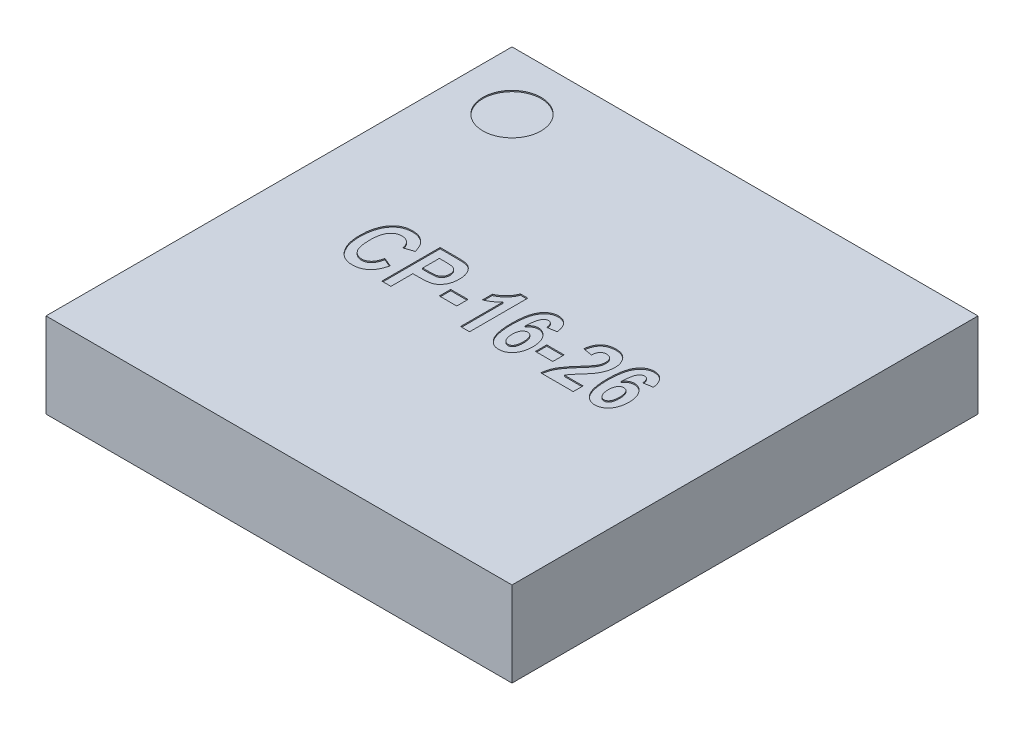
from build123d import *

# Parameters (mm, degrees)
SKETCH1_W           = 4
SKETCH1_H           = 4
BOSS_EXTRUDE1_DEPTH = 0.73
SKETCH2_R           = 0.25
CUT_EXTRUDE1_DEPTH  = 0.01
SKETCH3_W           = 0.14935065
SKETCH3_H           = 0.097402598
SKETCH3_W_2         = 0.149350649
CUT_EXTRUDE2_DEPTH  = 0.01


with BuildPart() as part:
    # Sketch1 → Boss-Extrude1 (new body)
    with BuildSketch(Plane(origin=(0, 0, 0), x_dir=(1, 0, 0), z_dir=(0, 1, 0))):
        Rectangle(SKETCH1_W, SKETCH1_H)
    extrude(amount=BOSS_EXTRUDE1_DEPTH)

    # Sketch2 → Cut-Extrude1 (cut)
    with BuildSketch(Plane(origin=(0, 0.73, 0), x_dir=(1, 0, 0), z_dir=(0, 1, 0))):
        with Locations(Location((-1.5, 1.5, 0), (0, 0, 270))):
            Circle(SKETCH2_R)
    extrude(amount=-CUT_EXTRUDE1_DEPTH, mode=Mode.SUBTRACT)

    # Sketch3 → Cut-Extrude2 (cut)
    with BuildSketch(Plane(origin=(0, 0.73, 0), x_dir=(1, 0, 0), z_dir=(0, 1, 0))):
        with BuildLine():
            Line((-0.973076704, -0.118181818), (-0.895154626, -0.150649351))
            add(Edge.make_bspline(
                [(-0.895154626, -0.150649351), (-0.896763939, -0.157199419), (-0.899899765, -0.169962551), (-0.905832316, -0.188204654), (-0.91236041, -0.205130547), (-0.919828916, -0.22064549), (-0.927981778, -0.2348856), (-0.937037949, -0.24771075), (-0.946827045, -0.259186605), (-0.957404745, -0.269286352), (-0.968753893, -0.277976376), (-0.980555836, -0.28572007), (-0.993115333, -0.29206825), (-1.006256518, -0.297428311), (-1.020082704, -0.301412625), (-1.034488844, -0.304410987), (-1.049536773, -0.306126789), (-1.059787871, -0.306369892), (-1.065000405, -0.306493506)],
                knots=[0, 0, 0, 0, 1.282586353, 2.499182829, 3.646034602, 4.730797578, 5.771318175, 6.763713287, 7.712684321, 8.6363956, 9.539720391, 10.428356747, 11.317388874, 12.212151588, 13.124116906, 14.050177375, 15.008543639, 16, 16, 16, 16], degree=3))
            add(Edge.make_bspline(
                [(-1.065000405, -0.306493506), (-1.071540548, -0.306346468), (-1.084352535, -0.306058423), (-1.103047685, -0.302959131), (-1.120837731, -0.298250296), (-1.137690604, -0.29148838), (-1.15362629, -0.282845212), (-1.168476442, -0.272139378), (-1.182587573, -0.259769439), (-1.190792225, -0.250124533), (-1.194971996, -0.245211039)],
                knots=[0, 0, 0, 0, 1.053414494, 2.063614103, 3.046293227, 4.01520277, 4.983805463, 5.961130836, 6.961320097, 8, 8, 8, 8], degree=3))
            add(Edge.make_bspline(
                [(-1.194971996, -0.245211039), (-1.199566404, -0.239144714), (-1.208822264, -0.226923542), (-1.220442483, -0.206770852), (-1.230325702, -0.185120172), (-1.23841463, -0.161951881), (-1.244719522, -0.13724031), (-1.249127461, -0.110973678), (-1.251774562, -0.083164691), (-1.252120533, -0.064109002), (-1.252297483, -0.054362825)],
                knots=[0, 0, 0, 0, 0.898140554, 1.809387162, 2.740718204, 3.705966939, 4.703925369, 5.74945803, 6.848943185, 8, 8, 8, 8], degree=3))
            add(Edge.make_bspline(
                [(-1.252297483, -0.054362825), (-1.252135827, -0.044074357), (-1.251820947, -0.024034148), (-1.248985936, 0.005142491), (-1.244664082, 0.032649117), (-1.238220378, 0.058383494), (-1.230148219, 0.082493389), (-1.220175089, 0.104828456), (-1.208595285, 0.125622287), (-1.199147489, 0.138041064), (-1.194464691, 0.144196429)],
                knots=[0, 0, 0, 0, 1.171098873, 2.281104103, 3.334483992, 4.338438261, 5.297974877, 6.225356982, 7.120398547, 8, 8, 8, 8], degree=3))
            add(Edge.make_bspline(
                [(-1.194464691, 0.144196429), (-1.190212941, 0.14917207), (-1.181833655, 0.158977992), (-1.167511461, 0.171675972), (-1.152124929, 0.182469708), (-1.135679624, 0.191307035), (-1.118101962, 0.19818042), (-1.099477972, 0.203030388), (-1.079733085, 0.205892063), (-1.066227429, 0.206289961), (-1.059318587, 0.206493506)],
                knots=[0, 0, 0, 0, 1.017460211, 2.005195831, 2.96880208, 3.936538458, 4.903086366, 5.898753713, 6.925103759, 8, 8, 8, 8], degree=3))
            add(Edge.make_bspline(
                [(-1.059318587, 0.206493506), (-1.053664634, 0.206358172), (-1.042552054, 0.206092177), (-1.02625747, 0.203965699), (-1.010732874, 0.200226584), (-0.995826721, 0.195322032), (-0.981669791, 0.188759793), (-0.968221148, 0.180796898), (-0.955427905, 0.171459527), (-0.947673719, 0.164200592), (-0.943754463, 0.160531656)],
                knots=[0, 0, 0, 0, 1.062174293, 2.087653736, 3.080296642, 4.058948008, 5.03139012, 6.005719887, 6.992016441, 8, 8, 8, 8], degree=3))
            add(Edge.make_bspline(
                [(-0.943754463, 0.160531656), (-0.941029443, 0.157703941), (-0.935476619, 0.151941852), (-0.927999728, 0.142235974), (-0.921077424, 0.13154683), (-0.914833817, 0.119828804), (-0.909029334, 0.107196426), (-0.903751219, 0.093584945), (-0.899107948, 0.078963394), (-0.896492758, 0.068824301), (-0.895154626, 0.063636364)],
                knots=[0, 0, 0, 0, 0.858002413, 1.748367619, 2.673305357, 3.63929672, 4.648357542, 5.711115493, 6.828831091, 8, 8, 8, 8], degree=3))
            Line((-0.895154626, 0.063636364), (-0.973076704, 0.037662338))
            add(Edge.make_bspline(
                [(-0.973076704, 0.037662338), (-0.973808933, 0.040987951), (-0.97523373, 0.047459042), (-0.978094361, 0.056797707), (-0.981577064, 0.065471471), (-0.98536629, 0.073688559), (-0.98992915, 0.081164757), (-0.994702044, 0.08825728), (-1.00029871, 0.09454098), (-1.006211433, 0.100346042), (-1.012648771, 0.105362577), (-1.019237965, 0.109899251), (-1.026175464, 0.113671163), (-1.03343233, 0.116704728), (-1.040922612, 0.119159799), (-1.048702123, 0.120886266), (-1.056753061, 0.121931755), (-1.062223945, 0.122028715), (-1.065000405, 0.122077922)],
                knots=[0, 0, 0, 0, 1.200071046, 2.335138942, 3.437621639, 4.493482591, 5.51985659, 6.521917265, 7.50210956, 8.480124453, 9.438987346, 10.374745328, 11.297656865, 12.216555725, 13.143999084, 14.072438006, 15.021767148, 16, 16, 16, 16], degree=3))
            add(Edge.make_bspline(
                [(-1.065000405, 0.122077922), (-1.068929785, 0.12196142), (-1.076663206, 0.121732133), (-1.087993334, 0.119907877), (-1.098713174, 0.116681277), (-1.108984117, 0.112445387), (-1.118633574, 0.106801919), (-1.127768964, 0.0999676), (-1.136144648, 0.091735893), (-1.144171857, 0.082476634), (-1.151445867, 0.07174862), (-1.157621998, 0.059349888), (-1.162716186, 0.045324702), (-1.167104227, 0.029773649), (-1.170387289, 0.012594558), (-1.172665633, -0.006185968), (-1.174087576, -0.026540695), (-1.174277256, -0.040663143), (-1.174375405, -0.047970779)],
                knots=[0, 0, 0, 0, 0.827686898, 1.628972485, 2.409099021, 3.181967192, 3.964173723, 4.757978677, 5.579415306, 6.433460257, 7.33665582, 8.302235029, 9.343905073, 10.476376866, 11.703364719, 13.024698166, 14.460435141, 16, 16, 16, 16], degree=3))
            add(Edge.make_bspline(
                [(-1.174375405, -0.047970779), (-1.174264501, -0.055547936), (-1.174050934, -0.070139244), (-1.172806011, -0.091213985), (-1.170439707, -0.110576844), (-1.167410658, -0.128303959), (-1.163265689, -0.144291712), (-1.158201808, -0.158549895), (-1.152369023, -0.171217707), (-1.145411136, -0.182128944), (-1.13770166, -0.191548589), (-1.129505076, -0.199726893), (-1.120663142, -0.206558729), (-1.111412401, -0.21234867), (-1.101498884, -0.216736134), (-1.091039872, -0.219721266), (-1.080097393, -0.221785937), (-1.072586065, -0.221979291), (-1.068754463, -0.222077922)],
                knots=[0, 0, 0, 0, 1.588381619, 3.058741945, 4.422565575, 5.675514383, 6.825848758, 7.879737597, 8.8437938, 9.742560847, 10.584031071, 11.391113559, 12.163968987, 12.921455088, 13.673648094, 14.427376256, 15.197789283, 16, 16, 16, 16], degree=3))
            add(Edge.make_bspline(
                [(-1.068754463, -0.222077922), (-1.065944307, -0.22199089), (-1.060369744, -0.221818242), (-1.052166727, -0.220718873), (-1.044250952, -0.218753222), (-1.036621354, -0.216026103), (-1.029310448, -0.212428018), (-1.022243224, -0.208165333), (-1.015562451, -0.203041538), (-1.009094776, -0.197223721), (-1.002994592, -0.190532204), (-0.997419491, -0.182838844), (-0.992239591, -0.174281141), (-0.987486208, -0.164806021), (-0.983129027, -0.154474384), (-0.979287274, -0.143206945), (-0.975810844, -0.131059958), (-0.974005638, -0.122557215), (-0.973076704, -0.118181818)],
                knots=[0, 0, 0, 0, 0.874040642, 1.73385169, 2.568061146, 3.406503852, 4.248567505, 5.09821747, 5.96915136, 6.862782357, 7.800986125, 8.779254107, 9.812897901, 10.908933612, 12.073249979, 13.297367906, 14.609261928, 16, 16, 16, 16], degree=3))
        make_face()
        with BuildLine():
            Line((-0.817232548, -0.3), (-0.817232548, 0.2))
            Line((-0.817232548, 0.2), (-0.682492288, 0.2))
            add(Edge.make_bspline(
                [(-0.682492288, 0.2), (-0.676506055, 0.199978894), (-0.665040044, 0.199938468), (-0.648666442, 0.199680898), (-0.633885466, 0.199050328), (-0.620758852, 0.198268717), (-0.609250063, 0.19728203), (-0.599405721, 0.196060775), (-0.591132358, 0.194778211), (-0.586264417, 0.193411113), (-0.58407508, 0.192796266)],
                knots=[0, 0, 0, 0, 1.45237712, 2.781878126, 3.972677768, 5.041396282, 5.972228918, 6.774219171, 7.448710173, 8, 8, 8, 8], degree=3))
            add(Edge.make_bspline(
                [(-0.58407508, 0.192796266), (-0.581044762, 0.191731788), (-0.575015397, 0.189613815), (-0.566299606, 0.185501934), (-0.558002232, 0.180549176), (-0.550144372, 0.174706292), (-0.542719161, 0.168076827), (-0.535664038, 0.160632241), (-0.529132382, 0.152288585), (-0.522899412, 0.143245054), (-0.517241573, 0.133470711), (-0.512328069, 0.12295398), (-0.508331928, 0.111709638), (-0.504827395, 0.099843654), (-0.502223082, 0.087250793), (-0.500431121, 0.073993169), (-0.499290731, 0.060071219), (-0.499131974, 0.050550155), (-0.49905073, 0.04567776)],
                knots=[0, 0, 0, 0, 0.846149961, 1.683567978, 2.535100776, 3.389102938, 4.260422696, 5.155850399, 6.088615247, 7.050446182, 8.048882284, 9.061856799, 10.105243332, 11.191356413, 12.320760927, 13.490669576, 14.715852464, 16, 16, 16, 16], degree=3))
            add(Edge.make_bspline(
                [(-0.49905073, 0.04567776), (-0.499097377, 0.041245033), (-0.499189021, 0.032536483), (-0.500256924, 0.019771051), (-0.501838249, 0.007532477), (-0.504152847, -0.004135746), (-0.50722735, -0.015239251), (-0.510884023, -0.025813078), (-0.51509828, -0.035894341), (-0.520108127, -0.045313008), (-0.525570873, -0.05409955), (-0.531377636, -0.062284165), (-0.537511576, -0.069749543), (-0.544022337, -0.076526498), (-0.550729836, -0.082767331), (-0.558010988, -0.088074434), (-0.565429557, -0.092941533), (-0.573427693, -0.097108949), (-0.582356815, -0.100563844), (-0.592485852, -0.103631762), (-0.604063439, -0.106105913), (-0.617079745, -0.108085171), (-0.631533635, -0.109692148), (-0.647403459, -0.110896543), (-0.664730046, -0.111606538), (-0.676742136, -0.111660304), (-0.682999593, -0.111688312)],
                knots=[0, 0, 0, 0, 1.135396723, 2.23060449, 3.279591759, 4.295786631, 5.275377901, 6.228987074, 7.160814112, 8.071657328, 8.958908755, 9.810053931, 10.641024385, 11.43162038, 12.216736813, 12.984447025, 13.736746148, 14.488596033, 15.289898233, 16.186242141, 17.197511819, 18.320073528, 19.558272269, 20.922626145, 22.396903763, 24, 24, 24, 24], degree=3))
            Line((-0.682999593, -0.111688312), (-0.73931047, -0.111688312))
            Line((-0.73931047, -0.111688312), (-0.73931047, -0.3))
            Line((-0.73931047, -0.3), (-0.817232548, -0.3))
        make_face()
        with BuildLine():
            Line((-0.73931047, 0.115584416), (-0.73931047, -0.027272727))
            Line((-0.73931047, -0.027272727), (-0.688478489, -0.027272727))
            add(Edge.make_bspline(
                [(-0.688478489, -0.027272727), (-0.684386018, -0.027255014), (-0.676538054, -0.027221045), (-0.66527331, -0.026917143), (-0.655021864, -0.026425177), (-0.645784181, -0.025725411), (-0.637589279, -0.024844774), (-0.630412102, -0.023723247), (-0.624263546, -0.022465533), (-0.617474305, -0.020460522), (-0.610030234, -0.017024981), (-0.601966556, -0.011749513), (-0.594759598, -0.005120391), (-0.588456328, 0.002712585), (-0.583253723, 0.011715126), (-0.579634823, 0.021821924), (-0.57730765, 0.032821603), (-0.577087011, 0.040490702), (-0.576972808, 0.044460227)],
                knots=[0, 0, 0, 0, 1.284283312, 2.462817476, 3.536098701, 4.504784959, 5.369772942, 6.121838585, 6.783804212, 7.337847747, 8.3400838, 9.343892165, 10.350558075, 11.399797468, 12.488501389, 13.596588458, 14.755994231, 16, 16, 16, 16], degree=3))
            add(Edge.make_bspline(
                [(-0.576972808, 0.044460227), (-0.577077394, 0.048499219), (-0.577279719, 0.056312732), (-0.5797385, 0.067471943), (-0.583409042, 0.077730611), (-0.588909908, 0.086705817), (-0.595235052, 0.094605746), (-0.602378721, 0.101271073), (-0.610434049, 0.106232085), (-0.617763387, 0.109420324), (-0.624493582, 0.111310853), (-0.630864798, 0.112330506), (-0.638443717, 0.113331868), (-0.647267926, 0.114278415), (-0.657324799, 0.114828493), (-0.668623951, 0.115204666), (-0.681171434, 0.1155409), (-0.689966328, 0.115569472), (-0.694566152, 0.115584416)],
                knots=[0, 0, 0, 0, 1.217310155, 2.3549115, 3.434183208, 4.491984437, 5.51587148, 6.484436833, 7.425091316, 8.358344432, 8.888574254, 9.53159621, 10.304262475, 11.197434113, 12.210261746, 13.34451227, 14.611151563, 16, 16, 16, 16], degree=3))
            Line((-0.694566152, 0.115584416), (-0.73931047, 0.115584416))
        make_face(mode=Mode.SUBTRACT)
        with Locations((-0.385414366, -0.114935065)):
            Rectangle(SKETCH3_W, SKETCH3_H)
        with BuildLine():
            Line((-0.063985795, -0.3), (-0.141907873, -0.3))
            Line((-0.141907873, -0.3), (-0.141907873, 0.063636364))
            add(Edge.make_bspline(
                [(-0.141907873, 0.063636364), (-0.145687077, 0.059670682), (-0.153182123, 0.051805807), (-0.165106191, 0.040826148), (-0.177442654, 0.030703473), (-0.190272917, 0.021391888), (-0.203450172, 0.012803013), (-0.217141118, 0.005050422), (-0.231229664, -0.001882073), (-0.240942365, -0.00582074), (-0.245803976, -0.007792208)],
                knots=[0, 0, 0, 0, 1.033480345, 2.049633457, 3.05634389, 4.043072978, 5.039658923, 6.022790494, 7.010324124, 8, 8, 8, 8], degree=3))
            Line((-0.245803976, -0.007792208), (-0.245803976, 0.076623377))
            add(Edge.make_bspline(
                [(-0.245803976, 0.076623377), (-0.24020024, 0.079113926), (-0.228533577, 0.084299109), (-0.211465855, 0.094709877), (-0.194228143, 0.10774717), (-0.179925092, 0.120261945), (-0.168769238, 0.131396363), (-0.160820295, 0.140166089), (-0.153703941, 0.149428979), (-0.147108896, 0.158854386), (-0.141285903, 0.168711853), (-0.136145015, 0.17881214), (-0.131583266, 0.189221134), (-0.129203775, 0.196394344), (-0.12800771, 0.2)],
                knots=[0, 0, 0, 0, 1.256071058, 2.615068939, 4.086222451, 5.682781329, 6.506361962, 7.316438188, 8.106904776, 8.89922375, 9.673254088, 10.451495518, 11.221635059, 12, 12, 12, 12], degree=3))
            Line((-0.12800771, 0.2), (-0.063985795, 0.2))
            Line((-0.063985795, 0.2), (-0.063985795, -0.3))
        make_face()
        with BuildLine():
            Line((0.312637582, 0.076623377), (0.234715504, 0.063636364))
            add(Edge.make_bspline(
                [(0.234715504, 0.063636364), (0.234202755, 0.068216652), (0.233237085, 0.07684281), (0.230428096, 0.088816516), (0.226601048, 0.098969751), (0.221871074, 0.107446183), (0.215872571, 0.114038938), (0.20879519, 0.118723313), (0.200669819, 0.121627802), (0.19490018, 0.121923899), (0.191898946, 0.122077922)],
                knots=[0, 0, 0, 0, 1.373243514, 2.586259675, 3.655479581, 4.599729819, 5.463161835, 6.285339117, 7.108072655, 8, 8, 8, 8], degree=3))
            add(Edge.make_bspline(
                [(0.191898946, 0.122077922), (0.189894974, 0.122013132), (0.185942821, 0.121885355), (0.180176915, 0.120462965), (0.174621151, 0.118337407), (0.16931264, 0.115258755), (0.164333388, 0.111249086), (0.159652898, 0.106404372), (0.155154818, 0.100797684), (0.150916663, 0.094163817), (0.146994783, 0.086200284), (0.143625209, 0.076539063), (0.140506332, 0.065185419), (0.137799183, 0.052032157), (0.135530489, 0.037089141), (0.133503199, 0.020377024), (0.13189261, 0.00190014), (0.131187387, -0.011002674), (0.1308194, -0.01773539)],
                knots=[0, 0, 0, 0, 0.57681816, 1.13757792, 1.702731885, 2.288308197, 2.89917272, 3.540654263, 4.227684296, 4.969066731, 5.806621519, 6.781650045, 7.915194099, 9.200750153, 10.65206053, 12.273281648, 14.055390695, 16, 16, 16, 16], degree=3))
            add(Edge.make_bspline(
                [(0.1308194, -0.01773539), (0.133224484, -0.014371673), (0.137886848, -0.007850954), (0.145715498, 0.000825783), (0.154025125, 0.00809695), (0.162665291, 0.014160845), (0.171800093, 0.018896642), (0.181418087, 0.022296591), (0.191552005, 0.02422322), (0.198452325, 0.024523431), (0.201943589, 0.024675325)],
                knots=[0, 0, 0, 0, 1.147521788, 2.224523334, 3.235995272, 4.207625523, 5.148408325, 6.08392744, 7.030550333, 8, 8, 8, 8], degree=3))
            add(Edge.make_bspline(
                [(0.201943589, 0.024675325), (0.205806329, 0.024527693), (0.21348354, 0.024234274), (0.224808378, 0.022221268), (0.235667746, 0.01855079), (0.246211911, 0.013662961), (0.256348206, 0.00734273), (0.266111655, -0.000383406), (0.275393635, -0.009556568), (0.284268876, -0.019962095), (0.292522252, -0.03146011), (0.299557979, -0.044108767), (0.305703369, -0.057553565), (0.310714883, -0.071943371), (0.314375593, -0.087293727), (0.317110977, -0.1035284), (0.318907936, -0.120644282), (0.31905568, -0.132381738), (0.319131089, -0.138372565)],
                knots=[0, 0, 0, 0, 0.832425701, 1.654448883, 2.468028177, 3.296231587, 4.153771285, 5.035920905, 5.973927841, 6.961291119, 7.980526655, 9.018328838, 10.075100388, 11.163029314, 12.296112419, 13.471533877, 14.709464618, 16, 16, 16, 16], degree=3))
            add(Edge.make_bspline(
                [(0.319131089, -0.138372565), (0.319014193, -0.144768861), (0.318786759, -0.157213546), (0.317028082, -0.175315501), (0.314249477, -0.192359904), (0.310173329, -0.208338581), (0.305001835, -0.223315309), (0.298745882, -0.237295338), (0.291200476, -0.250138136), (0.282567982, -0.261783591), (0.273142585, -0.272237288), (0.263102818, -0.281408819), (0.252498684, -0.289184459), (0.241349047, -0.295553816), (0.229592692, -0.300471668), (0.21724397, -0.303867968), (0.20439189, -0.306108179), (0.195628684, -0.306363929), (0.191188718, -0.306493506)],
                knots=[0, 0, 0, 0, 1.298310801, 2.526003934, 3.688615663, 4.800999101, 5.869304757, 6.90177424, 7.905043286, 8.886892483, 9.839696817, 10.758318684, 11.642716176, 12.503696962, 13.359295193, 14.222244813, 15.099282568, 16, 16, 16, 16], degree=3))
            add(Edge.make_bspline(
                [(0.191188718, -0.306493506), (0.18630444, -0.306325923), (0.176659934, -0.305995012), (0.162583061, -0.303127252), (0.149088173, -0.298694819), (0.136360871, -0.292163007), (0.124140306, -0.283994166), (0.112695741, -0.273858199), (0.101892052, -0.261956386), (0.091659443, -0.248286984), (0.082342766, -0.232472141), (0.074522234, -0.214186593), (0.067716021, -0.19366439), (0.062365741, -0.170686087), (0.057985781, -0.145422136), (0.055055631, -0.117731302), (0.053211017, -0.087701246), (0.053004405, -0.066879309), (0.052897322, -0.056087662)],
                knots=[0, 0, 0, 0, 0.734895461, 1.451125905, 2.155006623, 2.867987769, 3.598350511, 4.363563395, 5.163940447, 6.015576444, 6.931075895, 7.920946637, 9.004953514, 10.183535322, 11.470589844, 12.864423707, 14.374885431, 16, 16, 16, 16], degree=3))
            add(Edge.make_bspline(
                [(0.052897322, -0.056087662), (0.052998799, -0.045126962), (0.05319472, -0.02396512), (0.055118006, 0.006581141), (0.058330931, 0.034759896), (0.062725125, 0.060524164), (0.068332975, 0.083969917), (0.075406034, 0.104987565), (0.083669331, 0.123696696), (0.093257263, 0.140037295), (0.104042284, 0.15403478), (0.115309143, 0.166386255), (0.127431765, 0.176838936), (0.140377736, 0.185302049), (0.15402453, 0.191887892), (0.168384644, 0.196571658), (0.183492174, 0.199523425), (0.193846869, 0.199839545), (0.199102679, 0.2)],
                knots=[0, 0, 0, 0, 1.596357934, 3.082091073, 4.455719871, 5.725606172, 6.886943433, 7.963391173, 8.951248094, 9.861153463, 10.715374579, 11.520636501, 12.292728753, 13.040114141, 13.767206519, 14.493146518, 15.235155081, 16, 16, 16, 16], degree=3))
            add(Edge.make_bspline(
                [(0.199102679, 0.2), (0.20272626, 0.199898306), (0.209866198, 0.199697927), (0.22032875, 0.198242396), (0.230369967, 0.195929906), (0.239966694, 0.192561872), (0.249119496, 0.188154792), (0.257871355, 0.182882107), (0.266167125, 0.176625738), (0.273955495, 0.169397723), (0.281320727, 0.161287307), (0.287921831, 0.15208159), (0.29379714, 0.141903934), (0.298959493, 0.130746645), (0.303575454, 0.118671598), (0.307232544, 0.105499768), (0.310433991, 0.091423663), (0.311890565, 0.08164067), (0.312637582, 0.076623377)],
                knots=[0, 0, 0, 0, 0.93854164, 1.849311203, 2.731304215, 3.604197958, 4.478146452, 5.358702106, 6.247156056, 7.16485332, 8.107883078, 9.080606978, 10.093501812, 11.147913945, 12.262634196, 13.438487054, 14.686305819, 16, 16, 16, 16], degree=3))
        make_face()
        with BuildLine():
            add(Edge.make_bspline(
                [(0.137312907, -0.135227273), (0.137386535, -0.138880842), (0.137529839, -0.145991786), (0.138201172, -0.156362598), (0.139464449, -0.166072283), (0.141484592, -0.175089158), (0.143718979, -0.183466844), (0.146579468, -0.191191686), (0.150047932, -0.198208669), (0.153960978, -0.204559088), (0.15824922, -0.210169031), (0.162722544, -0.215028626), (0.167260757, -0.219284227), (0.172070074, -0.222576617), (0.17689307, -0.22537486), (0.181999655, -0.227133129), (0.187211628, -0.228320259), (0.190742567, -0.228487715), (0.192507712, -0.228571429)],
                knots=[0, 0, 0, 0, 1.467223306, 2.855657976, 4.171252668, 5.393844483, 6.563474186, 7.65065082, 8.69526462, 9.701480453, 10.641263037, 11.525539169, 12.352257717, 13.132142237, 13.8615626, 14.583230387, 15.291745363, 16, 16, 16, 16], degree=3))
            add(Edge.make_bspline(
                [(0.192507712, -0.228571429), (0.195894777, -0.228358066), (0.202586854, -0.22793651), (0.212033778, -0.223883771), (0.220453866, -0.217434056), (0.226517034, -0.210224638), (0.230745798, -0.203210577), (0.233600575, -0.196992003), (0.235856026, -0.189912915), (0.237917133, -0.182141304), (0.239427679, -0.173554472), (0.240352337, -0.164191838), (0.241143423, -0.154044384), (0.241186611, -0.146998565), (0.241209011, -0.143344156)],
                knots=[0, 0, 0, 0, 1.10939644, 2.191917695, 3.319954251, 4.574866243, 5.263603829, 6.010279106, 6.819397753, 7.704415383, 8.653663817, 9.683155171, 10.79833729, 12, 12, 12, 12], degree=3))
            add(Edge.make_bspline(
                [(0.241209011, -0.143344156), (0.241179799, -0.139555237), (0.241123407, -0.132240638), (0.240419887, -0.121670474), (0.239191223, -0.111921659), (0.237609373, -0.102926468), (0.23549698, -0.094752762), (0.232957025, -0.08733995), (0.229953945, -0.08070759), (0.225306153, -0.073233839), (0.218853667, -0.065353363), (0.209789671, -0.058361121), (0.199677221, -0.053944124), (0.192550524, -0.053480537), (0.188956576, -0.053246753)],
                knots=[0, 0, 0, 0, 1.176453253, 2.271171319, 3.287245332, 4.22660609, 5.105423138, 5.905880325, 6.657735779, 7.360218118, 8.634991581, 9.796584371, 10.888831116, 12, 12, 12, 12], degree=3))
            add(Edge.make_bspline(
                [(0.188956576, -0.053246753), (0.185470133, -0.053503053), (0.178514438, -0.054014388), (0.16861126, -0.058118834), (0.159660197, -0.064771574), (0.153247349, -0.072257596), (0.148618467, -0.079335477), (0.145573142, -0.085471194), (0.14307217, -0.092222063), (0.140897712, -0.099565483), (0.139347103, -0.107591502), (0.13810691, -0.116221664), (0.137398117, -0.125508928), (0.137341978, -0.1319117), (0.137312907, -0.135227273)],
                knots=[0, 0, 0, 0, 1.160949793, 2.316175707, 3.519822443, 4.855974483, 5.582526876, 6.339918642, 7.136761333, 7.98355107, 8.893612599, 9.862824193, 10.893297682, 12, 12, 12, 12], degree=3))
        make_face(mode=Mode.SUBTRACT)
        with Locations((0.439260959, -0.114935065)):
            Rectangle(SKETCH3_W_2, SKETCH3_H)
        with BuildLine():
            Line((0.825624595, -0.215584416), (0.825624595, -0.3))
            Line((0.825624595, -0.3), (0.546403816, -0.3))
            add(Edge.make_bspline(
                [(0.546403816, -0.3), (0.547386242, -0.291685939), (0.549348424, -0.275080406), (0.555290005, -0.250708492), (0.563299168, -0.226899299), (0.572069231, -0.207512093), (0.580772421, -0.191858397), (0.588558014, -0.179086255), (0.597829811, -0.165495387), (0.608576734, -0.151104208), (0.620493127, -0.135699462), (0.63384254, -0.119442718), (0.648555451, -0.102319659), (0.65893769, -0.090701863), (0.664301543, -0.084699675)],
                knots=[0, 0, 0, 0, 1.20268352, 2.402099407, 3.598367202, 4.810420478, 5.454599206, 6.172593709, 6.960183653, 7.818888272, 8.754527026, 9.759992126, 10.842728215, 12, 12, 12, 12], degree=3))
            add(Edge.make_bspline(
                [(0.664301543, -0.084699675), (0.668507153, -0.080009116), (0.676552859, -0.071035657), (0.687869844, -0.058041245), (0.698049438, -0.046356105), (0.70676723, -0.035739007), (0.714330408, -0.026411948), (0.720598426, -0.018232745), (0.725646455, -0.011272303), (0.728344626, -0.006893052), (0.729540991, -0.004951299)],
                knots=[0, 0, 0, 0, 1.465870871, 2.804341841, 4.009590698, 5.071600616, 6.000740577, 6.80347298, 7.469461756, 8, 8, 8, 8], degree=3))
            add(Edge.make_bspline(
                [(0.729540991, -0.004951299), (0.732317574, 2.2587e-05), (0.737737525, 0.009731723), (0.743381548, 0.025117569), (0.747070712, 0.040531154), (0.747493471, 0.050899733), (0.747702517, 0.056026786)],
                knots=[0, 0, 0, 0, 1.060288104, 2.069705834, 3.04550853, 4, 4, 4, 4], degree=3))
            add(Edge.make_bspline(
                [(0.747702517, 0.056026786), (0.747522961, 0.061149495), (0.74718305, 0.070847112), (0.744274005, 0.084396331), (0.739410789, 0.096048473), (0.732381493, 0.105509038), (0.723823957, 0.112935219), (0.713953464, 0.118354284), (0.702782476, 0.12156447), (0.694930092, 0.121903332), (0.690884335, 0.122077922)],
                knots=[0, 0, 0, 0, 1.245810787, 2.358399634, 3.353971925, 4.295778042, 5.200327805, 6.09189762, 7.016895116, 8, 8, 8, 8], degree=3))
            add(Edge.make_bspline(
                [(0.690884335, 0.122077922), (0.686497139, 0.12188621), (0.678088308, 0.121518759), (0.666261613, 0.11809776), (0.65599665, 0.112458457), (0.647584824, 0.104273831), (0.640681023, 0.094048519), (0.63569662, 0.081479307), (0.632279207, 0.066804978), (0.631325403, 0.056249263), (0.6308194, 0.050649351)],
                knots=[0, 0, 0, 0, 0.999920937, 1.916523715, 2.784458762, 3.647604167, 4.570853193, 5.582015381, 6.717234977, 8, 8, 8, 8], degree=3))
            Line((0.6308194, 0.050649351), (0.552897322, 0.063636364))
            add(Edge.make_bspline(
                [(0.552897322, 0.063636364), (0.553549813, 0.069332466), (0.554815567, 0.080382229), (0.558167221, 0.096253679), (0.562136545, 0.11100631), (0.567106624, 0.124563774), (0.573000526, 0.136943755), (0.579838221, 0.148132606), (0.587422561, 0.1583186), (0.596136307, 0.16715758), (0.605631752, 0.174890528), (0.615844806, 0.181658918), (0.626850663, 0.187318568), (0.638553325, 0.192038085), (0.651058709, 0.195532196), (0.664239597, 0.198207098), (0.678200379, 0.199715818), (0.687735571, 0.199903879), (0.692609173, 0.2)],
                knots=[0, 0, 0, 0, 1.257113927, 2.438652199, 3.554660598, 4.606291011, 5.601856267, 6.557471959, 7.478981492, 8.381416587, 9.2725261, 10.161501808, 11.064119884, 11.98308707, 12.924775989, 13.908409216, 14.930951759, 16, 16, 16, 16], degree=3))
            add(Edge.make_bspline(
                [(0.692609173, 0.2), (0.697961363, 0.199913806), (0.708335379, 0.199746739), (0.723363346, 0.197578705), (0.737433848, 0.194489713), (0.750408439, 0.189684873), (0.762513958, 0.18390512), (0.773399698, 0.176422834), (0.783512172, 0.167942554), (0.792182267, 0.157874864), (0.800074613, 0.147233269), (0.806851092, 0.136017626), (0.812718427, 0.124525665), (0.817393873, 0.112551878), (0.821033796, 0.100189255), (0.823656955, 0.087464131), (0.825375163, 0.074370547), (0.825540589, 0.065501987), (0.825624595, 0.060998377)],
                knots=[0, 0, 0, 0, 1.185802577, 2.298411505, 3.360827086, 4.373838454, 5.359924385, 6.327149754, 7.295159843, 8.277960573, 9.264958702, 10.230903902, 11.180079425, 12.122922977, 13.076886226, 14.034409875, 15.001838751, 16, 16, 16, 16], degree=3))
            add(Edge.make_bspline(
                [(0.825624595, 0.060998377), (0.825539338, 0.055886592), (0.825370076, 0.04573815), (0.823631757, 0.030625849), (0.821064332, 0.015724148), (0.817255802, 0.001013003), (0.812330966, -0.013582419), (0.806333985, -0.028188479), (0.799228111, -0.042853115), (0.792230811, -0.055003638), (0.7859611, -0.065098102), (0.780378114, -0.073166685), (0.774015468, -0.081707118), (0.767051546, -0.090863101), (0.759213292, -0.100458392), (0.750691849, -0.110607178), (0.741457423, -0.121261769), (0.734996608, -0.128472551), (0.731671673, -0.132183442)],
                knots=[0, 0, 0, 0, 1.112568374, 2.208785751, 3.308090549, 4.402946702, 5.513734595, 6.659701235, 7.83876403, 9.059051271, 9.71083511, 10.425746939, 11.194567613, 12.029688168, 12.930202216, 13.891926091, 14.915120021, 16, 16, 16, 16], degree=3))
            add(Edge.make_bspline(
                [(0.731671673, -0.132183442), (0.72859288, -0.135598203), (0.722723109, -0.142108502), (0.714350823, -0.151431184), (0.707021322, -0.159983543), (0.700378362, -0.167454332), (0.69471224, -0.174062865), (0.689878504, -0.179727022), (0.686092314, -0.184613568), (0.68035758, -0.191752834), (0.673470394, -0.201802082), (0.668581783, -0.211106822), (0.666229303, -0.215584416)],
                knots=[0, 0, 0, 0, 1.297038255, 2.472825099, 3.534584971, 4.474279189, 5.292832013, 5.990344774, 6.574432518, 7.036342243, 8.573839243, 10, 10, 10, 10], degree=3))
            Line((0.666229303, -0.215584416), (0.825624595, -0.215584416))
        make_face()
        with BuildLine():
            Line((1.137312907, 0.076623377), (1.059390829, 0.063636364))
            add(Edge.make_bspline(
                [(1.059390829, 0.063636364), (1.05887808, 0.068216652), (1.057912409, 0.07684281), (1.055103421, 0.088816516), (1.051276373, 0.098969751), (1.046546399, 0.107446183), (1.040547895, 0.114038938), (1.033470515, 0.118723313), (1.025345143, 0.121627802), (1.019575504, 0.121923899), (1.01657427, 0.122077922)],
                knots=[0, 0, 0, 0, 1.373243514, 2.586259675, 3.655479581, 4.599729819, 5.463161835, 6.285339117, 7.108072655, 8, 8, 8, 8], degree=3))
            add(Edge.make_bspline(
                [(1.01657427, 0.122077922), (1.014570299, 0.122013132), (1.010618145, 0.121885355), (1.00485224, 0.120462965), (0.999296475, 0.118337407), (0.993987965, 0.115258755), (0.989008712, 0.111249086), (0.984328223, 0.106404372), (0.979830143, 0.100797684), (0.975591988, 0.094163817), (0.971670108, 0.086200284), (0.968300534, 0.076539063), (0.965181657, 0.065185419), (0.962474508, 0.052032157), (0.960205814, 0.037089141), (0.958178524, 0.020377024), (0.956567935, 0.00190014), (0.955862712, -0.011002674), (0.955494725, -0.01773539)],
                knots=[0, 0, 0, 0, 0.57681816, 1.13757792, 1.702731885, 2.288308197, 2.89917272, 3.540654263, 4.227684296, 4.969066731, 5.806621519, 6.781650045, 7.915194099, 9.200750153, 10.65206053, 12.273281648, 14.055390695, 16, 16, 16, 16], degree=3))
            add(Edge.make_bspline(
                [(0.955494725, -0.01773539), (0.957899809, -0.014371673), (0.962562173, -0.007850954), (0.970390822, 0.000825783), (0.978700449, 0.00809695), (0.987340615, 0.014160845), (0.996475417, 0.018896642), (1.006093412, 0.022296591), (1.016227329, 0.02422322), (1.02312765, 0.024523431), (1.026618913, 0.024675325)],
                knots=[0, 0, 0, 0, 1.147521788, 2.224523334, 3.235995272, 4.207625523, 5.148408325, 6.08392744, 7.030550333, 8, 8, 8, 8], degree=3))
            add(Edge.make_bspline(
                [(1.026618913, 0.024675325), (1.030481654, 0.024527693), (1.038158864, 0.024234274), (1.049483703, 0.022221268), (1.060343071, 0.01855079), (1.070887236, 0.013662961), (1.081023531, 0.00734273), (1.09078698, -0.000383406), (1.100068959, -0.009556568), (1.108944201, -0.019962095), (1.117197576, -0.03146011), (1.124233304, -0.044108767), (1.130378694, -0.057553565), (1.135390208, -0.071943371), (1.139050918, -0.087293727), (1.141786302, -0.1035284), (1.143583261, -0.120644282), (1.143731005, -0.132381738), (1.143806413, -0.138372565)],
                knots=[0, 0, 0, 0, 0.832425701, 1.654448883, 2.468028177, 3.296231587, 4.153771285, 5.035920905, 5.973927841, 6.961291119, 7.980526655, 9.018328838, 10.075100388, 11.163029314, 12.296112419, 13.471533877, 14.709464618, 16, 16, 16, 16], degree=3))
            add(Edge.make_bspline(
                [(1.143806413, -0.138372565), (1.143689517, -0.144768861), (1.143462083, -0.157213546), (1.141703407, -0.175315501), (1.138924802, -0.192359904), (1.134848653, -0.208338581), (1.129677159, -0.223315309), (1.123421207, -0.237295338), (1.115875801, -0.250138136), (1.107243307, -0.261783591), (1.09781791, -0.272237288), (1.087778143, -0.281408819), (1.077174009, -0.289184459), (1.066024371, -0.295553816), (1.054268017, -0.300471668), (1.041919294, -0.303867968), (1.029067214, -0.306108179), (1.020304009, -0.306363929), (1.015864043, -0.306493506)],
                knots=[0, 0, 0, 0, 1.298310801, 2.526003934, 3.688615663, 4.800999101, 5.869304757, 6.90177424, 7.905043286, 8.886892483, 9.839696817, 10.758318684, 11.642716176, 12.503696962, 13.359295193, 14.222244813, 15.099282568, 16, 16, 16, 16], degree=3))
            add(Edge.make_bspline(
                [(1.015864043, -0.306493506), (1.010979764, -0.306325923), (1.001335258, -0.305995012), (0.987258386, -0.303127252), (0.973763497, -0.298694819), (0.961036196, -0.292163007), (0.94881563, -0.283994166), (0.937371066, -0.273858199), (0.926567376, -0.261956386), (0.916334767, -0.248286984), (0.90701809, -0.232472141), (0.899197559, -0.214186593), (0.892391346, -0.19366439), (0.887041065, -0.170686087), (0.882661105, -0.145422136), (0.879730956, -0.117731302), (0.877886342, -0.087701246), (0.87767973, -0.066879309), (0.877572647, -0.056087662)],
                knots=[0, 0, 0, 0, 0.734895461, 1.451125905, 2.155006623, 2.867987769, 3.598350511, 4.363563395, 5.163940447, 6.015576444, 6.931075895, 7.920946637, 9.004953514, 10.183535322, 11.470589844, 12.864423707, 14.374885431, 16, 16, 16, 16], degree=3))
            add(Edge.make_bspline(
                [(0.877572647, -0.056087662), (0.877674124, -0.045126962), (0.877870045, -0.02396512), (0.879793331, 0.006581141), (0.883006256, 0.034759896), (0.88740045, 0.060524164), (0.8930083, 0.083969917), (0.900081359, 0.104987565), (0.908344655, 0.123696696), (0.917932588, 0.140037295), (0.928717608, 0.15403478), (0.939984467, 0.166386255), (0.95210709, 0.176838936), (0.965053061, 0.185302049), (0.978699855, 0.191887892), (0.993059969, 0.196571658), (1.008167499, 0.199523425), (1.018522194, 0.199839545), (1.023778004, 0.2)],
                knots=[0, 0, 0, 0, 1.596357934, 3.082091073, 4.455719871, 5.725606172, 6.886943433, 7.963391173, 8.951248094, 9.861153463, 10.715374579, 11.520636501, 12.292728753, 13.040114141, 13.767206519, 14.493146518, 15.235155081, 16, 16, 16, 16], degree=3))
            add(Edge.make_bspline(
                [(1.023778004, 0.2), (1.027401585, 0.199898306), (1.034541523, 0.199697927), (1.045004075, 0.198242396), (1.055045291, 0.195929906), (1.064642019, 0.192561872), (1.073794821, 0.188154792), (1.08254668, 0.182882107), (1.09084245, 0.176625738), (1.098630819, 0.169397723), (1.105996051, 0.161287307), (1.112597156, 0.15208159), (1.118472464, 0.141903934), (1.123634818, 0.130746645), (1.128250779, 0.118671598), (1.131907869, 0.105499768), (1.135109316, 0.091423663), (1.13656589, 0.08164067), (1.137312907, 0.076623377)],
                knots=[0, 0, 0, 0, 0.93854164, 1.849311203, 2.731304215, 3.604197958, 4.478146452, 5.358702106, 6.247156056, 7.16485332, 8.107883078, 9.080606978, 10.093501812, 11.147913945, 12.262634196, 13.438487054, 14.686305819, 16, 16, 16, 16], degree=3))
        make_face()
        with BuildLine():
            add(Edge.make_bspline(
                [(0.961988231, -0.135227273), (0.96206186, -0.138880842), (0.962205164, -0.145991786), (0.962876497, -0.156362598), (0.964139774, -0.166072283), (0.966159917, -0.175089158), (0.968394304, -0.183466844), (0.971254792, -0.191191686), (0.974723256, -0.198208669), (0.978636303, -0.204559088), (0.982924544, -0.210169031), (0.987397868, -0.215028626), (0.991936082, -0.219284227), (0.996745398, -0.222576617), (1.001568395, -0.22537486), (1.006674979, -0.227133129), (1.011886953, -0.228320259), (1.015417892, -0.228487715), (1.017183037, -0.228571429)],
                knots=[0, 0, 0, 0, 1.467223306, 2.855657976, 4.171252668, 5.393844483, 6.563474186, 7.65065082, 8.69526462, 9.701480453, 10.641263037, 11.525539169, 12.352257717, 13.132142237, 13.8615626, 14.583230387, 15.291745363, 16, 16, 16, 16], degree=3))
            add(Edge.make_bspline(
                [(1.017183037, -0.228571429), (1.020570101, -0.228358066), (1.027262179, -0.22793651), (1.036709102, -0.223883771), (1.045129191, -0.217434056), (1.051192359, -0.210224638), (1.055421123, -0.203210577), (1.058275899, -0.196992003), (1.06053135, -0.189912915), (1.062592457, -0.182141304), (1.064103004, -0.173554472), (1.065027662, -0.164191838), (1.065818748, -0.154044384), (1.065861935, -0.146998565), (1.065884335, -0.143344156)],
                knots=[0, 0, 0, 0, 1.10939644, 2.191917695, 3.319954251, 4.574866243, 5.263603829, 6.010279106, 6.819397753, 7.704415383, 8.653663817, 9.683155171, 10.79833729, 12, 12, 12, 12], degree=3))
            add(Edge.make_bspline(
                [(1.065884335, -0.143344156), (1.065855124, -0.139555237), (1.065798731, -0.132240638), (1.065095212, -0.121670474), (1.063866548, -0.111921659), (1.062284698, -0.102926468), (1.060172305, -0.094752762), (1.05763235, -0.08733995), (1.054629269, -0.08070759), (1.049981478, -0.073233839), (1.043528992, -0.065353363), (1.034464996, -0.058361121), (1.024352546, -0.053944124), (1.017225849, -0.053480537), (1.0136319, -0.053246753)],
                knots=[0, 0, 0, 0, 1.176453253, 2.271171319, 3.287245332, 4.22660609, 5.105423138, 5.905880325, 6.657735779, 7.360218118, 8.634991581, 9.796584371, 10.888831116, 12, 12, 12, 12], degree=3))
            add(Edge.make_bspline(
                [(1.0136319, -0.053246753), (1.010145458, -0.053503053), (1.003189763, -0.054014388), (0.993286585, -0.058118834), (0.984335522, -0.064771574), (0.977922674, -0.072257596), (0.973293792, -0.079335477), (0.970248466, -0.085471194), (0.967747495, -0.092222063), (0.965573037, -0.099565483), (0.964022428, -0.107591502), (0.962782235, -0.116221664), (0.962073442, -0.125508928), (0.962017302, -0.1319117), (0.961988231, -0.135227273)],
                knots=[0, 0, 0, 0, 1.160949793, 2.316175707, 3.519822443, 4.855974483, 5.582526876, 6.339918642, 7.136761333, 7.98355107, 8.893612599, 9.862824193, 10.893297682, 12, 12, 12, 12], degree=3))
        make_face(mode=Mode.SUBTRACT)
    extrude(amount=-CUT_EXTRUDE2_DEPTH, mode=Mode.SUBTRACT)


solid = part.part
